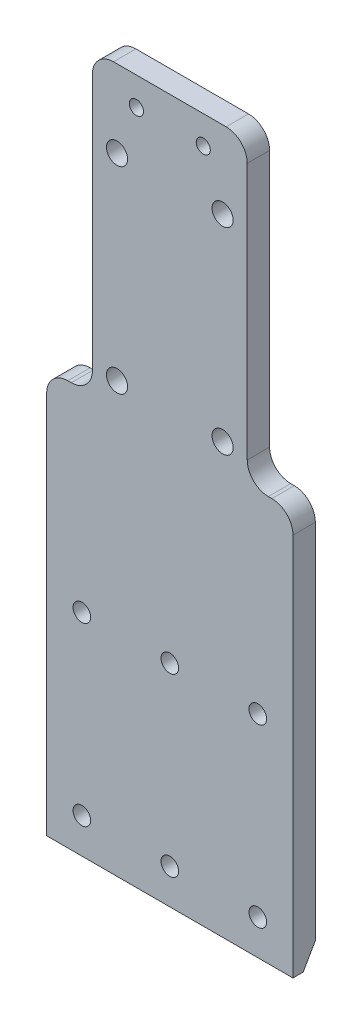
from build123d import *

# Parameters (mm, degrees)
SKETCH1_W           = 35
SKETCH1_H           = 100
BOSS_EXTRUDE1_DEPTH = 3.175
SKETCH2_R           = 1.5
SKETCH2_W           = 6.5
SKETCH2_H           = 42.5
CUT_EXTRUDE1_DEPTH  = 4.175
FILLET1_R           = 3
CHAMFER1_SIZE       = 3
CHAMFER1_SIZE2      = 1.732050808
SKETCH3_R           = 1
CUT_EXTRUDE2_DEPTH  = 4.175
SKETCH4_R           = 1.25
CUT_EXTRUDE3_DEPTH  = 4.175


with BuildPart() as part:
    # Sketch1 → Boss-Extrude1 (new body)
    with BuildSketch(Plane.XY):
        Rectangle(SKETCH1_W, SKETCH1_H)
    extrude(amount=BOSS_EXTRUDE1_DEPTH)

    # Sketch2 → Cut-Extrude1 (cut, through all)
    with BuildSketch(Plane.XY.offset(3.175)):
        with Locations((-7.5, 39)):
            Circle(SKETCH2_R)
        with Locations((-7.5, 11)):
            Circle(SKETCH2_R)
        with Locations((7.5, 11)):
            Circle(SKETCH2_R)
        with Locations((7.5, 39)):
            Circle(SKETCH2_R)
        with Locations((-14.25, 28.75)):
            Rectangle(SKETCH2_W, SKETCH2_H)
        with Locations((14.25, 28.75)):
            Rectangle(SKETCH2_W, SKETCH2_H)
    extrude(amount=-CUT_EXTRUDE1_DEPTH, mode=Mode.SUBTRACT)

    # Fillet1
    fillet1_edges = [part.edges().sort_by_distance(p)[0] for p in [
        (-17.5, 7.5, 1.5875),
        (-11, 50, 1.5875),
        (-11, 7.5, 1.5875),
        (11, 7.5, 1.5875),
        (11, 50, 1.5875),
        (17.5, 7.5, 1.5875),
    ]]
    fillet(fillet1_edges, radius=FILLET1_R)

    # Chamfer1
    chamfer1_edges = [part.edges().sort_by_distance(p)[0] for p in [
        (0, -50, 0),
    ]]
    chamfer1_side = [part.faces().sort_by_distance(p)[0] for p in [
        (0, -5.754552851, 0),
    ]]
    chamfer(chamfer1_edges, length=CHAMFER1_SIZE, length2=CHAMFER1_SIZE2, reference=chamfer1_side[0])

    # Sketch3 → Cut-Extrude2 (cut, through all)
    with BuildSketch(Plane.XY.offset(3.175)):
        with Locations((-4.75, 46)):
            Circle(SKETCH3_R)
        with Locations((4.75, 46)):
            Circle(SKETCH3_R)
    extrude(amount=-CUT_EXTRUDE2_DEPTH, mode=Mode.SUBTRACT)

    # Sketch4 → Cut-Extrude3 (cut, through all)
    with BuildSketch(Plane.XY.offset(3.175)):
        with Locations((-12.5, -45)):
            Circle(SKETCH4_R)
        with Locations((12.5, -45)):
            Circle(SKETCH4_R)
        with Locations((-12.5, -20)):
            Circle(SKETCH4_R)
        with Locations((12.5, -20)):
            Circle(SKETCH4_R)
        with Locations((0, -45)):
            Circle(SKETCH4_R)
        with Locations((0, -20)):
            Circle(SKETCH4_R)
    extrude(amount=-CUT_EXTRUDE3_DEPTH, mode=Mode.SUBTRACT)


solid = part.part
